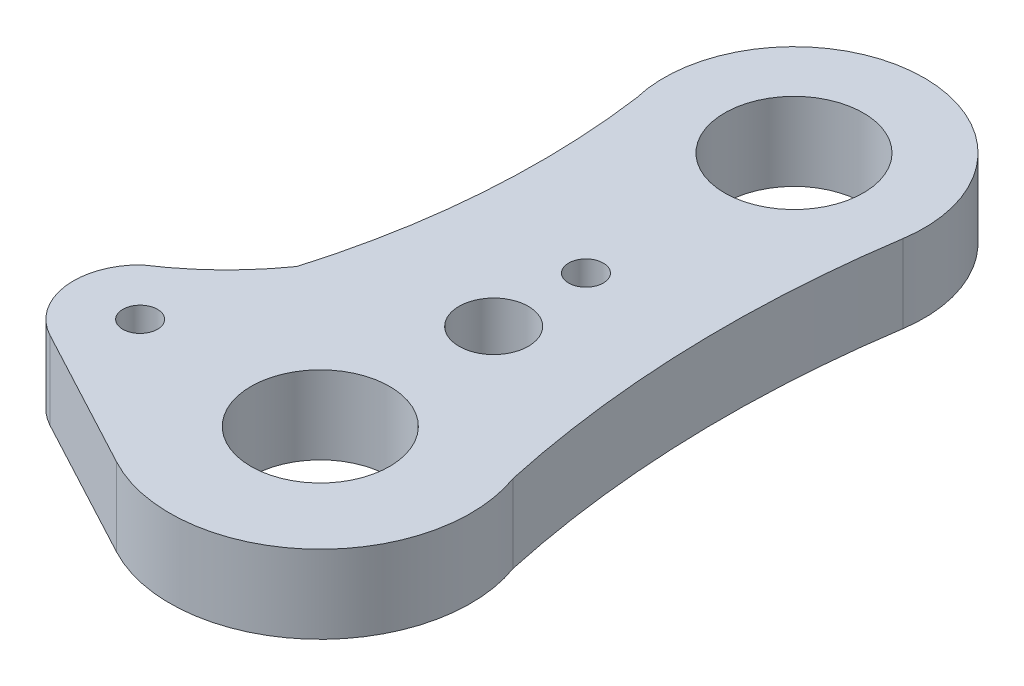
from build123d import *

# Parameters (mm, degrees)
SKETCH1_R           = 1
SKETCH1_R_2         = 4
SKETCH1_R_3         = 2
BOSS_EXTRUDE1_DEPTH = 4.5


with BuildPart() as part:
    # Sketch1 → Boss-Extrude1 (new body)
    with BuildSketch(Plane(origin=(0, 0, 0), x_dir=(1, 0, 0), z_dir=(0, 1, 0))):
        with BuildLine():
            ThreePointArc((-13.216577068, -12.398039355), (-14.355594067, -15.696551109), (-12.358546854, -18.55825374))
            Line((-12.358546854, -18.55825374), (-4.089079858, -22.975728551))
            ThreePointArc((-4.089079858, -22.975728551), (5.687833956, -21.875689807), (8.154517998, -12.351321125))
            ThreePointArc((8.154517998, -12.351321125), (6.724685531, -0.7813357), (7.419863607, 10.855919606))
            ThreePointArc((7.419863607, 10.855919606), (-0.324076795, 19.500551353), (-7.293531269, 10.220197086))
            ThreePointArc((-7.293531269, 10.220197086), (-7.006184901, 1.034726978), (-8.662387246, -8.004765421))
            ThreePointArc((-8.662387246, -8.004765421), (-10.314906991, -10.000536559), (-12.253567388, -11.719699089))
            ThreePointArc((-12.253567388, -11.719699089), (-12.729149831, -12.067276987), (-13.216577068, -12.398039355))
        make_face()
        with Locations((-10.546429397, -15.165988669)):
            Circle(SKETCH1_R, mode=Mode.SUBTRACT)
        with Locations((0, -15.321013501)):
            Circle(SKETCH1_R_2, mode=Mode.SUBTRACT)
        with Locations((0, -5.321013501)):
            Circle(SKETCH1_R_3, mode=Mode.SUBTRACT)
        Circle(SKETCH1_R, mode=Mode.SUBTRACT)
        with Locations((-3e-08, 12)):
            Circle(SKETCH1_R_2, mode=Mode.SUBTRACT)
    extrude(amount=BOSS_EXTRUDE1_DEPTH)


solid = part.part
